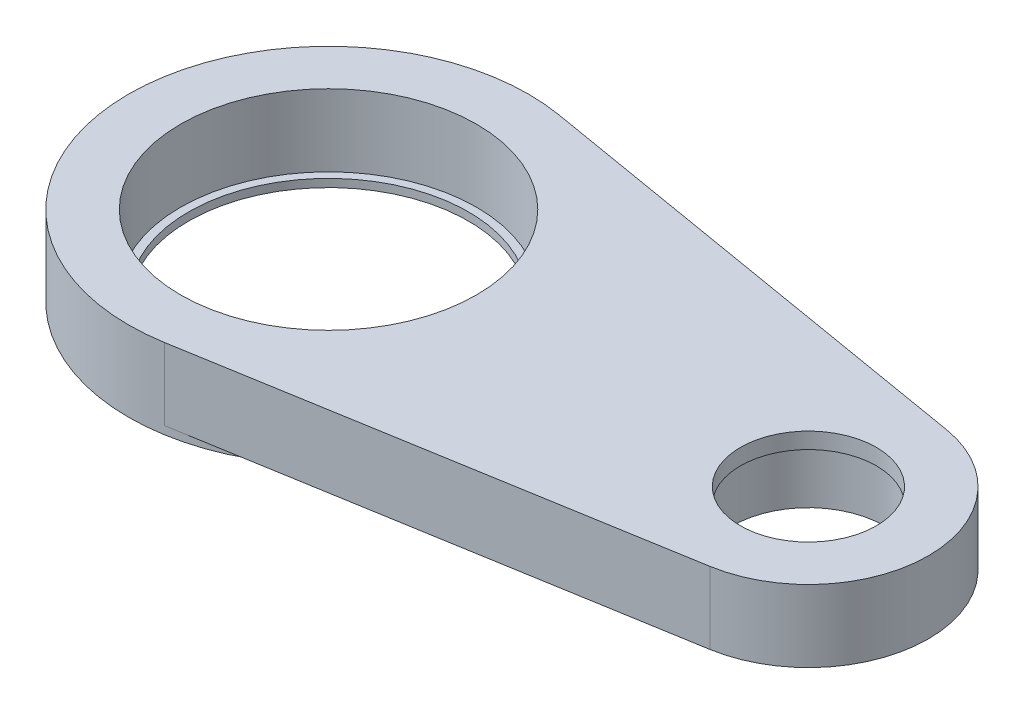
from build123d import *

# Parameters (mm, degrees)
SKETCH_1_R           = 25
SKETCH_1_R_2         = 17.5
EXTRUDE_1_DEPTH      = 5
SKETCH_2_R           = 25
SKETCH_2_R_2         = 18.5
EXTRUDE_2_DEPTH      = 5
EXTRUDE_3_DEPTH      = 9
SKETCH_7_R           = 18.5
CUT_EXTRUDE_4_DEPTH  = 4
SKETCH_13_R          = 9.5
CUT_EXTRUDE_9_DEPTH  = 7
SKETCH_14_R          = 8.5
CUT_EXTRUDE_10_DEPTH = 3


with BuildPart() as part:
    # 스케치1 → 보스-돌출1 (new body)
    with BuildSketch(Plane(origin=(0, 0, 0), x_dir=(1, 0, 0), z_dir=(0, 1, 0))):
        Circle(SKETCH_1_R)
        Circle(SKETCH_1_R_2, mode=Mode.SUBTRACT)
    extrude(amount=EXTRUDE_1_DEPTH)

    # 스케치2 → 보스-돌출2 (add)
    with BuildSketch(Plane(origin=(0, 5, 0), x_dir=(1, 0, 0), z_dir=(0, 1, 0))):
        Circle(SKETCH_2_R)
        Circle(SKETCH_2_R_2, mode=Mode.SUBTRACT)
    extrude(amount=EXTRUDE_2_DEPTH)

    # 스케치3 → 보스-돌출3 (add)
    with BuildSketch(Plane(origin=(0, 10, 0), x_dir=(1, 0, 0), z_dir=(0, 1, 0))):
        with BuildLine():
            Line((4.166666667, 24.65033243), (62.5, 14.790199458))
            ThreePointArc((62.5, 14.790199458), (75, 0), (62.5, -14.790199458))
            Line((62.5, -14.790199458), (4.166666667, -24.65033243))
            ThreePointArc((4.166666667, -24.65033243), (25, 0), (4.166666667, 24.65033243))
        make_face()
    extrude(amount=-EXTRUDE_3_DEPTH)

    # 스케치7 → 컷-돌출4 (cut)
    with BuildSketch(Plane(origin=(0, 5, 0), x_dir=(1, 0, 0), z_dir=(0, 1, 0))):
        Circle(SKETCH_7_R)
    extrude(amount=-CUT_EXTRUDE_4_DEPTH, mode=Mode.SUBTRACT)

    # 스케치13 → 컷-돌출9 (cut)
    with BuildSketch(Plane.XZ.offset(-1)):
        with Locations((60, 0)):
            Circle(SKETCH_13_R)
    extrude(amount=-CUT_EXTRUDE_9_DEPTH, mode=Mode.SUBTRACT)

    # 스케치14 → 컷-돌출10 (cut, through all)
    with BuildSketch(Plane.XZ.offset(-8)):
        with Locations((60, 0)):
            Circle(SKETCH_14_R)
    extrude(amount=-CUT_EXTRUDE_10_DEPTH, mode=Mode.SUBTRACT)


solid = part.part
